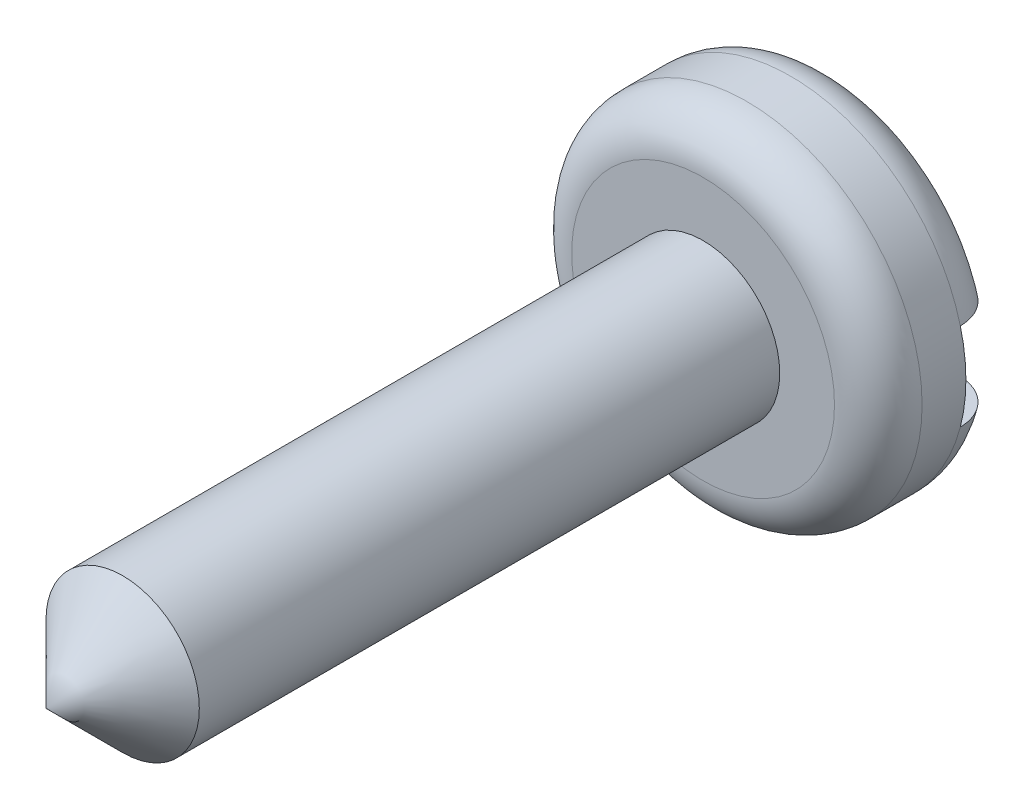
from build123d import *

# Parameters (mm, degrees)
SKETCH1_R           = 4
BOSS_EXTRUDE1_DEPTH = 3
SKETCH2_R           = 1.75
BOSS_EXTRUDE2_DEPTH = 15
FILLET2_R           = 1
SKETCH3_W           = 11.938810874
SKETCH3_H           = 2
CUT_EXTRUDE1_DEPTH  = 1
CHAMFER1_SIZE       = 1.75


with BuildPart() as part:
    # Sketch1 → Boss-Extrude1 (new body)
    with BuildSketch(Plane.XY):
        Circle(SKETCH1_R)
    extrude(amount=BOSS_EXTRUDE1_DEPTH)

    # Sketch2 → Boss-Extrude2 (add)
    with BuildSketch(Plane.XY.offset(3)):
        Circle(SKETCH2_R)
    extrude(amount=BOSS_EXTRUDE2_DEPTH)

    # Fillet2
    fillet2_edges = [part.edges().sort_by_distance(p)[0] for p in [
        (-4, 0, 0),
        (-4, 0, 3),
    ]]
    fillet(fillet2_edges, radius=FILLET2_R)

    # Sketch3 → Cut-Extrude1 (cut)
    with BuildSketch(Plane(origin=(0, 0, 0), x_dir=(-1, 0, 0), z_dir=(0, 0, -1))):
        with Locations((-0.202329925, 0)):
            Rectangle(SKETCH3_W, SKETCH3_H)
    extrude(amount=-CUT_EXTRUDE1_DEPTH, mode=Mode.SUBTRACT)

    # Chamfer1
    chamfer1_edges = [part.edges().sort_by_distance(p)[0] for p in [
        (-1.75, 0, 18),
    ]]
    chamfer(chamfer1_edges, length=CHAMFER1_SIZE)


solid = part.part
